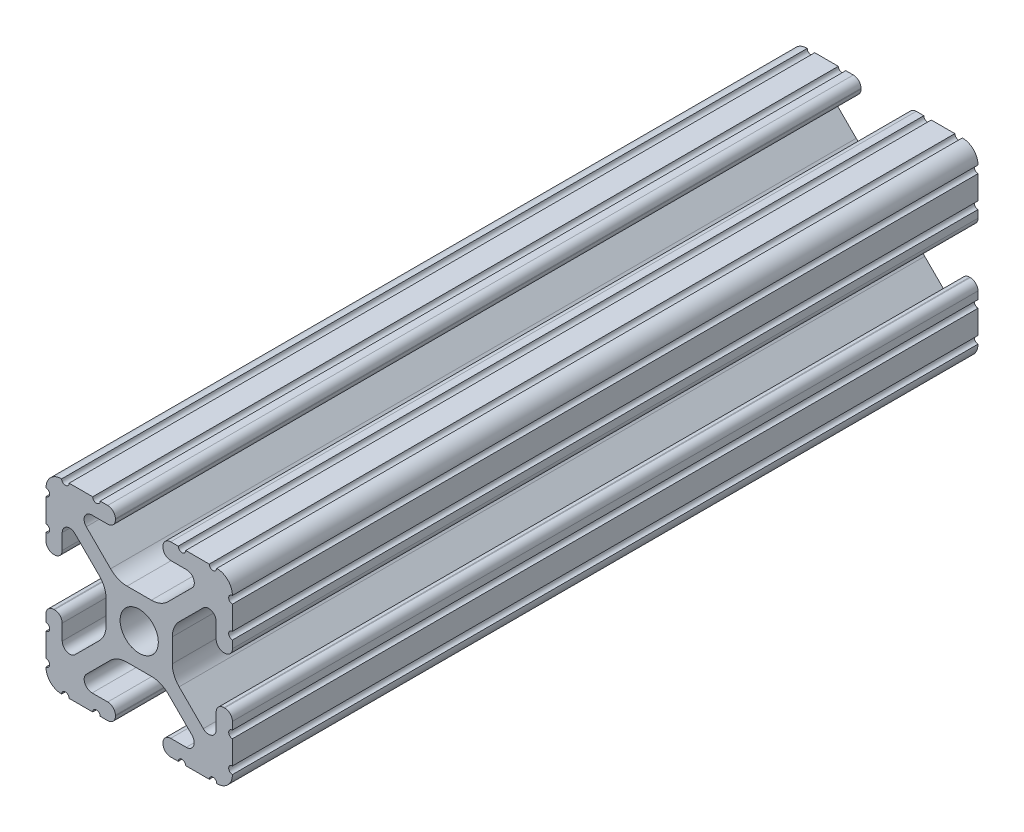
from build123d import *

# Parameters (mm, degrees)
SKETCH1_R      = 2.6035
EXTRUDE1_DEPTH = 101.6


with BuildPart() as part:
    # Sketch1 → Extrude1 (new body)
    with BuildSketch(Plane.XY):
        with BuildLine():
            Line((-7.207191475, 8.724540082), (-3.900315394, 5.423689619))
            ThreePointArc((-3.900315394, 5.423689619), (-2.8709819, 4.736928798), (-1.657299581, 4.4958))
            Line((-1.657299581, 4.4958), (1.657299581, 4.4958))
            ThreePointArc((1.657299581, 4.4958), (2.8709819, 4.736928798), (3.900315394, 5.423689619))
            Line((3.900315394, 5.423689619), (7.207191475, 8.724540082))
            ThreePointArc((7.207191475, 8.724540082), (7.43216212, 9.851515102), (6.476774195, 10.4902))
            Line((6.476774195, 10.4902), (4.2874692, 10.4902))
            ThreePointArc((4.2874692, 10.4902), (3.545700044, 10.797450844), (3.2384492, 11.53922))
            Line((3.2384492, 11.53922), (3.2384492, 11.65098))
            ThreePointArc((3.2384492, 11.65098), (3.545700044, 12.392749156), (4.2874692, 12.7))
            Line((4.2874692, 12.7), (5.3170836, 12.7))
            ThreePointArc((5.3170836, 12.7), (5.8250836, 12.192), (6.3330836, 12.7))
            Line((6.3330836, 12.7), (9.5504, 12.7))
            ThreePointArc((9.5504, 12.7), (10.058323491, 12.192000006), (10.566399977, 12.699846982))
            ThreePointArc((10.566399977, 12.699846982), (12.082522516, 12.082522516), (12.699846982, 10.566399977))
            ThreePointArc((12.699846982, 10.566399977), (12.192000006, 10.058323491), (12.7, 9.5504))
            Line((12.7, 9.5504), (12.7, 6.3331344))
            ThreePointArc((12.7, 6.3331344), (12.192, 5.8251344), (12.7, 5.3171344))
            Line((12.7, 5.3171344), (12.7, 4.287470133))
            ThreePointArc((12.7, 4.287470133), (12.392749156, 3.545700977), (11.65098, 3.238450133))
            Line((11.65098, 3.238450133), (11.53922, 3.238450133))
            ThreePointArc((11.53922, 3.238450133), (10.797450844, 3.545700977), (10.4902, 4.287470133))
            Line((10.4902, 4.287470133), (10.4902, 6.402089023))
            ThreePointArc((10.4902, 6.402089023), (9.856394933, 7.351113629), (8.736962546, 7.129240479))
            Line((8.736962546, 7.129240479), (5.440484187, 3.838768792))
            ThreePointArc((5.440484187, 3.838768792), (4.75073678, 2.808015636), (4.5085, 1.591658411))
            Line((4.5085, 1.591658411), (4.5085, -1.591658411))
            ThreePointArc((4.5085, -1.591658411), (4.75073678, -2.808015636), (5.440484187, -3.838768792))
            Line((5.440484187, -3.838768792), (8.736962546, -7.129240479))
            ThreePointArc((8.736962546, -7.129240479), (9.856394933, -7.351113629), (10.4902, -6.402089023))
            Line((10.4902, -6.402089023), (10.4902, -4.287470133))
            ThreePointArc((10.4902, -4.287470133), (10.797450844, -3.545700977), (11.53922, -3.238450133))
            Line((11.53922, -3.238450133), (11.65098, -3.238450133))
            ThreePointArc((11.65098, -3.238450133), (12.392749156, -3.545700977), (12.7, -4.287470133))
            Line((12.7, -4.287470133), (12.7, -5.3170836))
            ThreePointArc((12.7, -5.3170836), (12.192, -5.8250836), (12.7, -6.3330836))
            Line((12.7, -6.3330836), (12.7, -9.5504))
            ThreePointArc((12.7, -9.5504), (12.192000006, -10.058323491), (12.699846982, -10.566399977))
            ThreePointArc((12.699846982, -10.566399977), (12.082522516, -12.082522516), (10.566399977, -12.699846982))
            ThreePointArc((10.566399977, -12.699846982), (10.058323491, -12.192000006), (9.5504, -12.7))
            Line((9.5504, -12.7), (6.3331344, -12.7))
            ThreePointArc((6.3331344, -12.7), (5.8251344, -12.192), (5.3171344, -12.7))
            Line((5.3171344, -12.7), (4.28752, -12.7))
            ThreePointArc((4.28752, -12.7), (3.545750844, -12.392749156), (3.2385, -11.65098))
            Line((3.2385, -11.65098), (3.2385, -11.53922))
            ThreePointArc((3.2385, -11.53922), (3.545750844, -10.797450844), (4.28752, -10.4902))
            Line((4.28752, -10.4902), (6.41641086, -10.4902))
            ThreePointArc((6.41641086, -10.4902), (7.414733441, -9.822812921), (7.179652728, -8.645192207))
            Line((7.179652728, -8.645192207), (3.95226937, -5.423689619))
            ThreePointArc((3.95226937, -5.423689619), (2.922935876, -4.736928798), (1.709253557, -4.4958))
            Line((1.709253557, -4.4958), (-1.709253557, -4.4958))
            ThreePointArc((-1.709253557, -4.4958), (-2.922935876, -4.736928798), (-3.95226937, -5.423689619))
            Line((-3.95226937, -5.423689619), (-7.179652728, -8.645192207))
            ThreePointArc((-7.179652728, -8.645192207), (-7.414733441, -9.822812921), (-6.41641086, -10.4902))
            Line((-6.41641086, -10.4902), (-4.28752, -10.4902))
            ThreePointArc((-4.28752, -10.4902), (-3.545750844, -10.797450844), (-3.2385, -11.53922))
            Line((-3.2385, -11.53922), (-3.2385, -11.65098))
            ThreePointArc((-3.2385, -11.65098), (-3.545750844, -12.392749156), (-4.28752, -12.7))
            Line((-4.28752, -12.7), (-5.3171344, -12.7))
            ThreePointArc((-5.3171344, -12.7), (-5.8251344, -12.192), (-6.3331344, -12.7))
            Line((-6.3331344, -12.7), (-9.5504, -12.7))
            ThreePointArc((-9.5504, -12.7), (-10.058323491, -12.192000006), (-10.566399977, -12.699846982))
            ThreePointArc((-10.566399977, -12.699846982), (-12.082522516, -12.082522516), (-12.699846982, -10.566399977))
            ThreePointArc((-12.699846982, -10.566399977), (-12.192000006, -10.058323491), (-12.7, -9.5504))
            Line((-12.7, -9.5504), (-12.7, -6.3330836))
            ThreePointArc((-12.7, -6.3330836), (-12.192, -5.8250836), (-12.7, -5.3170836))
            Line((-12.7, -5.3170836), (-12.7, -4.287470133))
            ThreePointArc((-12.7, -4.287470133), (-12.392749156, -3.545700977), (-11.65098, -3.238450133))
            Line((-11.65098, -3.238450133), (-11.53922, -3.238450133))
            ThreePointArc((-11.53922, -3.238450133), (-10.797450844, -3.545700977), (-10.4902, -4.287470133))
            Line((-10.4902, -4.287470133), (-10.4902, -6.402089023))
            ThreePointArc((-10.4902, -6.402089023), (-9.856394933, -7.351113629), (-8.736962546, -7.129240479))
            Line((-8.736962546, -7.129240479), (-5.440484187, -3.838768792))
            ThreePointArc((-5.440484187, -3.838768792), (-4.75073678, -2.808015636), (-4.5085, -1.591658411))
            Line((-4.5085, -1.591658411), (-4.5085, 1.591658411))
            ThreePointArc((-4.5085, 1.591658411), (-4.75073678, 2.808015636), (-5.440484187, 3.838768792))
            Line((-5.440484187, 3.838768792), (-8.736962546, 7.129240479))
            ThreePointArc((-8.736962546, 7.129240479), (-9.856394933, 7.351113629), (-10.4902, 6.402089023))
            Line((-10.4902, 6.402089023), (-10.4902, 4.287470133))
            ThreePointArc((-10.4902, 4.287470133), (-10.797450844, 3.545700977), (-11.53922, 3.238450133))
            Line((-11.53922, 3.238450133), (-11.65098, 3.238450133))
            ThreePointArc((-11.65098, 3.238450133), (-12.392749156, 3.545700977), (-12.7, 4.287470133))
            Line((-12.7, 4.287470133), (-12.7, 5.3171344))
            ThreePointArc((-12.7, 5.3171344), (-12.192, 5.8251344), (-12.7, 6.3331344))
            Line((-12.7, 6.3331344), (-12.7, 9.5504))
            ThreePointArc((-12.7, 9.5504), (-12.192000006, 10.058323491), (-12.699846982, 10.566399977))
            ThreePointArc((-12.699846982, 10.566399977), (-12.082522516, 12.082522516), (-10.566399977, 12.699846982))
            ThreePointArc((-10.566399977, 12.699846982), (-10.058323491, 12.192000006), (-9.5504, 12.7))
            Line((-9.5504, 12.7), (-6.3330836, 12.7))
            ThreePointArc((-6.3330836, 12.7), (-5.8250836, 12.192), (-5.3170836, 12.7))
            Line((-5.3170836, 12.7), (-4.2874692, 12.7))
            ThreePointArc((-4.2874692, 12.7), (-3.545700044, 12.392749156), (-3.2384492, 11.65098))
            Line((-3.2384492, 11.65098), (-3.2384492, 11.53922))
            ThreePointArc((-3.2384492, 11.53922), (-3.545700044, 10.797450844), (-4.2874692, 10.4902))
            Line((-4.2874692, 10.4902), (-6.476774195, 10.4902))
            ThreePointArc((-6.476774195, 10.4902), (-7.43216212, 9.851515102), (-7.207191475, 8.724540082))
        make_face()
        Circle(SKETCH1_R, mode=Mode.SUBTRACT)
    extrude(amount=-EXTRUDE1_DEPTH)


solid = part.part
